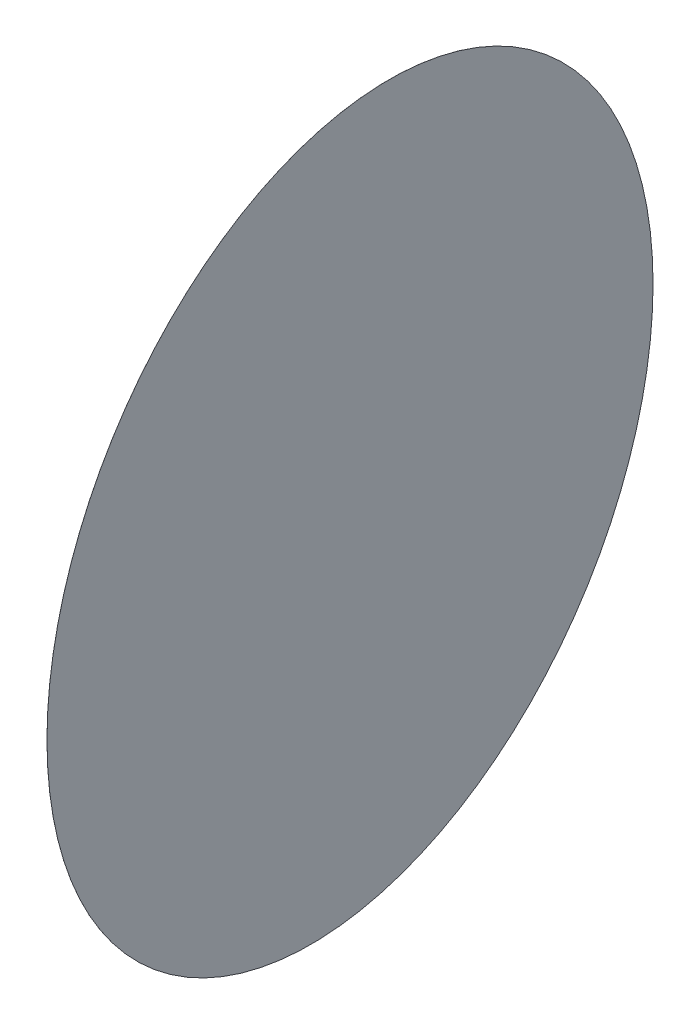
from build123d import *

# Parameters (mm, degrees)
SKETCH_1_R      = 15
EXTRUDE_1_DEPTH = 0.001


with BuildPart() as part:
    # 草图1 → 凸台-拉伸1 (new body)
    with BuildSketch(Plane(origin=(39.657794455, 0, -5.221047689), x_dir=(0.130526192, 0, 0.991444861), z_dir=(-0.991444861, 0, 0.130526192))):
        Circle(SKETCH_1_R)
    extrude(amount=-EXTRUDE_1_DEPTH)


solid = part.part
